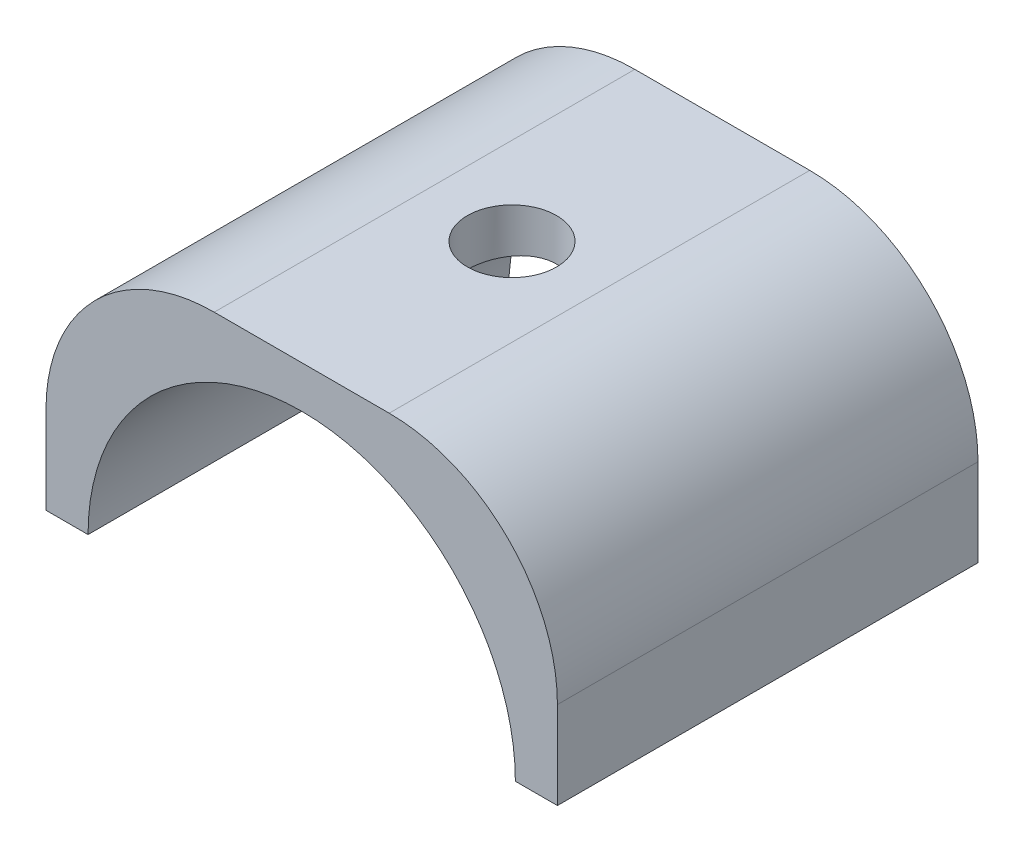
from build123d import *

# Parameters (mm, degrees)
BOSS_EXTRUDE1_DEPTH  = 12.5
M5_CLEARANCE_HOLE1_D = 5.3
SKETCH4_W            = 1
SKETCH4_H            = 20
CUT_EXTRUDE1_DEPTH   = 3


with BuildPart() as part:
    # Sketch1 → Boss-Extrude1 (new body, symmetric)
    with BuildSketch(Plane.XY):
        with BuildLine():
            Line((-15.2, 0), (-12.7, 0))
            ThreePointArc((-12.7, 0), (0, 12.7), (12.7, 0))
            Line((12.7, 0), (15.2, 0))
            Line((15.2, 0), (15.2, 5.2))
            ThreePointArc((15.2, 5.2), (12.271067812, 12.271067812), (5.2, 15.2))
            Line((5.2, 15.2), (-5.2, 15.2))
            ThreePointArc((-5.2, 15.2), (-12.271067812, 12.271067812), (-15.2, 5.2))
            Line((-15.2, 5.2), (-15.2, 0))
        make_face()
    extrude(amount=BOSS_EXTRUDE1_DEPTH, both=True)

    # M5 Clearance Hole1 (through all)
    with Locations(Plane(origin=(0, 15.2, 0), x_dir=(1, 0, 0), z_dir=(0, 1, 0))):
        with Locations((0, 0)):
            Hole(M5_CLEARANCE_HOLE1_D / 2)

    # Sketch4 → Cut-Extrude1 (cut)
    with BuildSketch(Plane.XZ):
        with Locations((-13.95, 0)):
            Rectangle(SKETCH4_W, SKETCH4_H)
        with Locations((13.95, 0)):
            Rectangle(SKETCH4_W, SKETCH4_H)
    extrude(amount=-CUT_EXTRUDE1_DEPTH, mode=Mode.SUBTRACT)


solid = part.part
